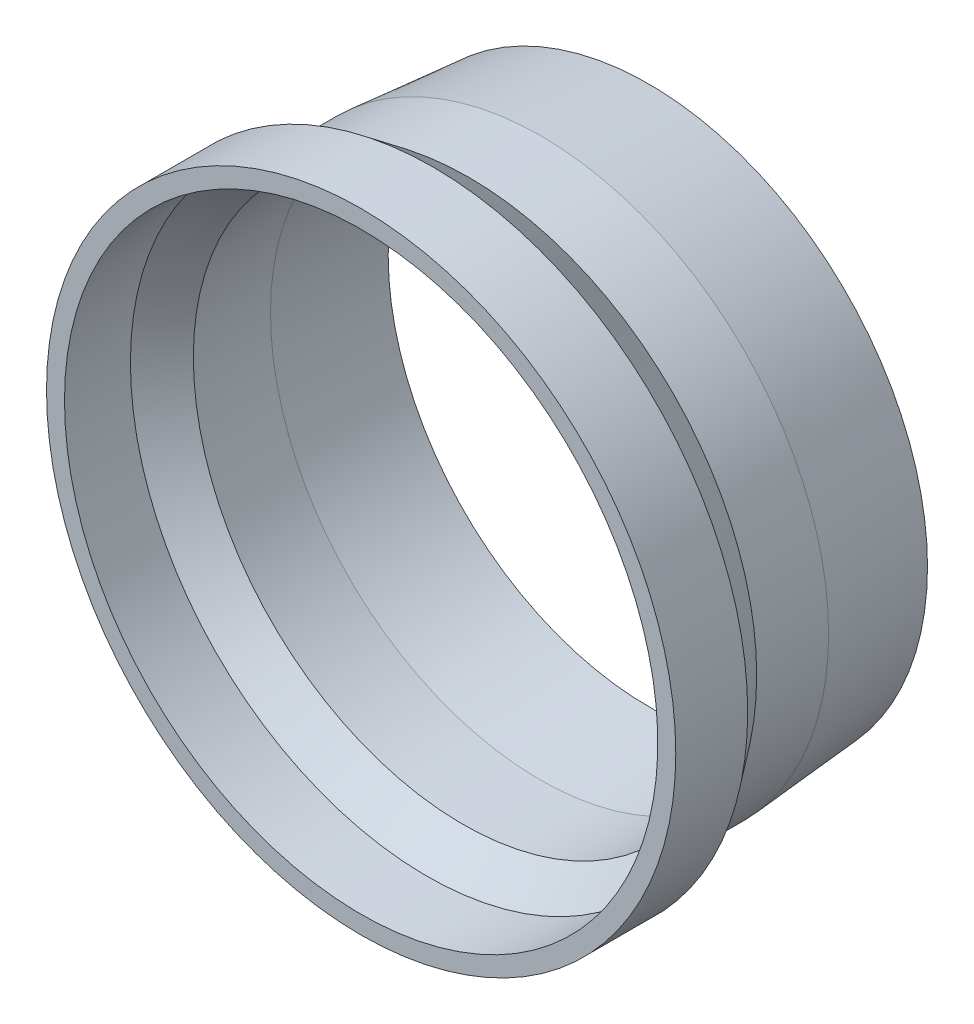
from build123d import *


with BuildPart() as part:
    # Sketch1 → Revolve1 (revolve)
    with BuildSketch(Plane(origin=(0, 0, 0), x_dir=(0, 0, -1), z_dir=(1, 0, 0))):
        Polygon((-39.158333333, 52.3875), (-32.808333333, 47.625), (-19.182062788, 47.625), (0, 46.026494768), (0, 49.2125), (-19.05, 50.8), (-31.75, 50.8), (-38.1, 55.5625), (-50.8, 55.5625), (-50.8, 52.3875), align=None)
    revolve(axis=Axis((0, 0, 0), (0, 0, 1)))


solid = part.part
